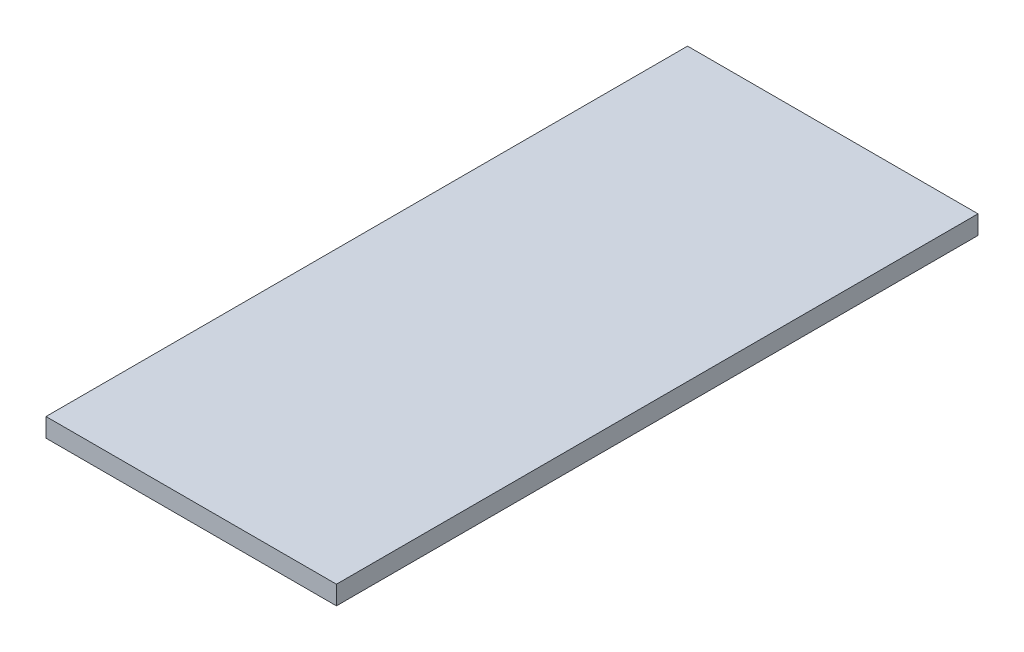
from build123d import *

# Parameters (mm, degrees)
SKETCH2_W           = 541
SKETCH2_H           = 1195
BOSS_EXTRUDE1_DEPTH = 35


with BuildPart() as part:
    # Sketch2 → Boss-Extrude1 (new body)
    with BuildSketch(Plane(origin=(0, 0, 0), x_dir=(1, 0, 0), z_dir=(0, 1, 0))):
        with Locations((213.907028553, 592.581062793)):
            Rectangle(SKETCH2_W, SKETCH2_H)
    extrude(amount=BOSS_EXTRUDE1_DEPTH)


solid = part.part
